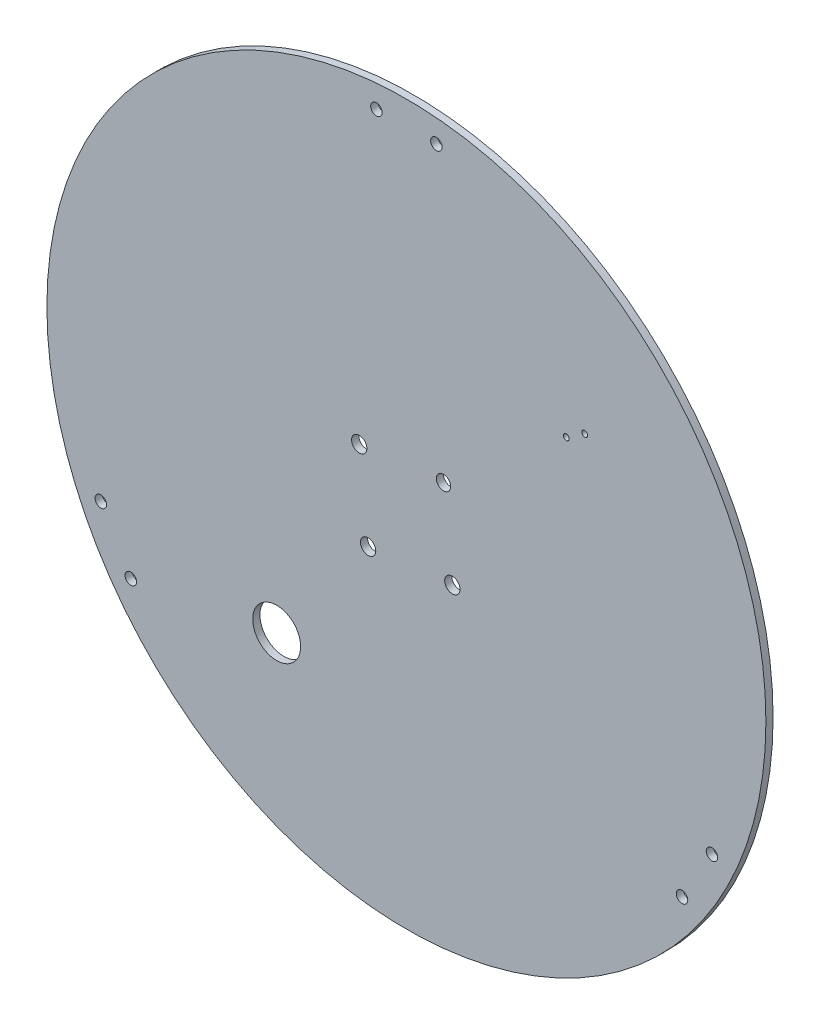
from build123d import *

# Parameters (mm, degrees)
SKETCH1_R           = 150
SKETCH1_R_2         = 2.4
SKETCH1_R_3         = 1.2
SKETCH1_R_4         = 3.2
SKETCH1_R_5         = 2.985295717
SKETCH1_R_6         = 10
BOSS_EXTRUDE2_DEPTH = 3


with BuildPart() as part:
    # Sketch1 → Boss-Extrude2 (new body)
    with BuildSketch(Plane.XY):
        with Locations((1.005166955, 1.283510016)):
            Circle(SKETCH1_R)
        with Locations((13.505166955, 141.283510016)):
            Circle(SKETCH1_R_2, mode=Mode.SUBTRACT)
        with Locations((-11.494833045, 141.283510016)):
            Circle(SKETCH1_R_2, mode=Mode.SUBTRACT)
        with Locations((128.498723485, -57.891172437)):
            Circle(SKETCH1_R_2, mode=Mode.SUBTRACT)
        with Locations((115.998723485, -79.541807531)):
            Circle(SKETCH1_R_2, mode=Mode.SUBTRACT)
        with Locations((-113.988389575, -79.541807531)):
            Circle(SKETCH1_R_2, mode=Mode.SUBTRACT)
        with Locations((-126.488389575, -57.891172437)):
            Circle(SKETCH1_R_2, mode=Mode.SUBTRACT)
        with Locations((75.411999641, 67.498838087)):
            Circle(SKETCH1_R_3, mode=Mode.SUBTRACT)
        with Locations((67.711999641, 62.398838087)):
            Circle(SKETCH1_R_3, mode=Mode.SUBTRACT)
        with Locations((20.182524253, -14.770377264)):
            Circle(SKETCH1_R_4, mode=Mode.SUBTRACT)
        with Locations((-14.97913456, -18.466016524)):
            Circle(SKETCH1_R_4, mode=Mode.SUBTRACT)
        with Locations((16.486884992, 20.391281549)):
            Circle(SKETCH1_R_5, mode=Mode.SUBTRACT)
        with Locations((-18.67477382, 16.695642288)):
            Circle(SKETCH1_R_4, mode=Mode.SUBTRACT)
        with Locations((-53.120643495, -68.716489984)):
            Circle(SKETCH1_R_6, mode=Mode.SUBTRACT)
    extrude(amount=BOSS_EXTRUDE2_DEPTH)


solid = part.part
